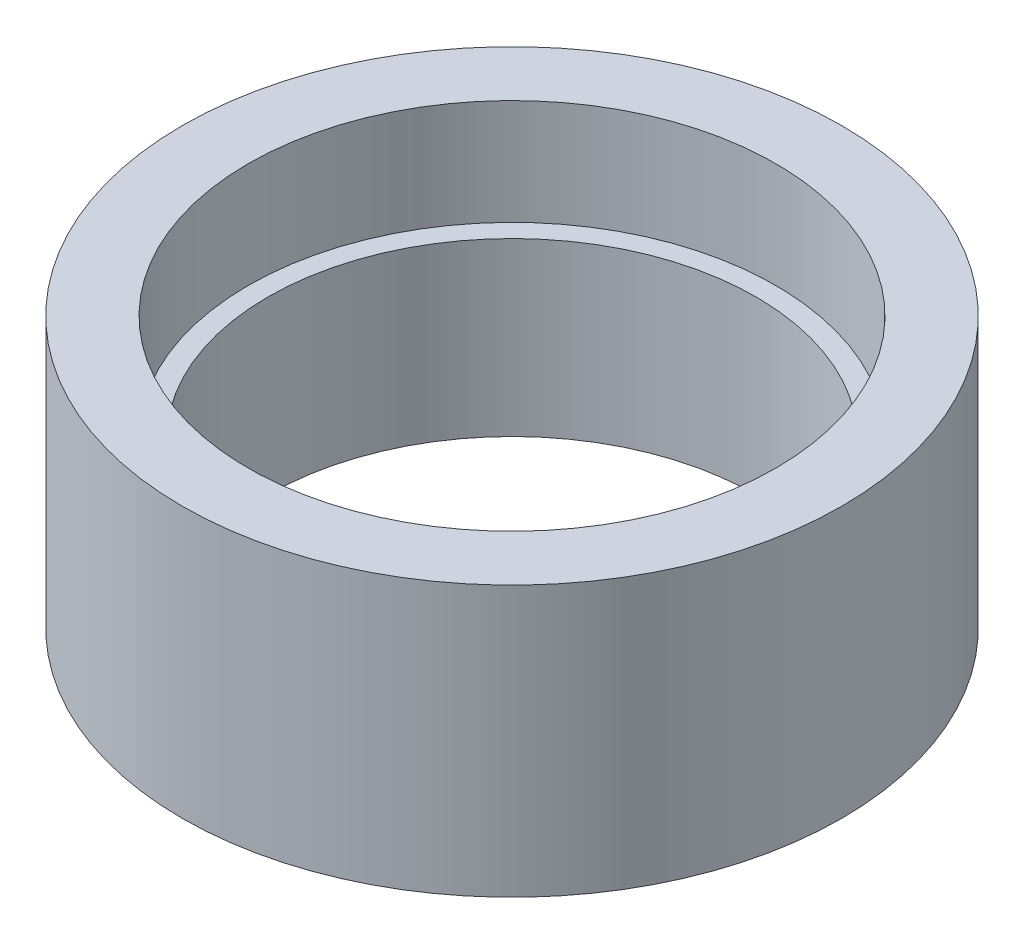
from build123d import *


with BuildPart() as part:
    # 草圖1 → 旋轉1 (revolve)
    with BuildSketch(Plane.XY):
        Polygon((40, 0), (50, 0), (50, -41), (40, -41), (40, -42), (37, -42), (37, -16), (40, -16), align=None)
    revolve(axis=Axis((0, 36.486224101, 0), (0, -1, 0)))


solid = part.part
